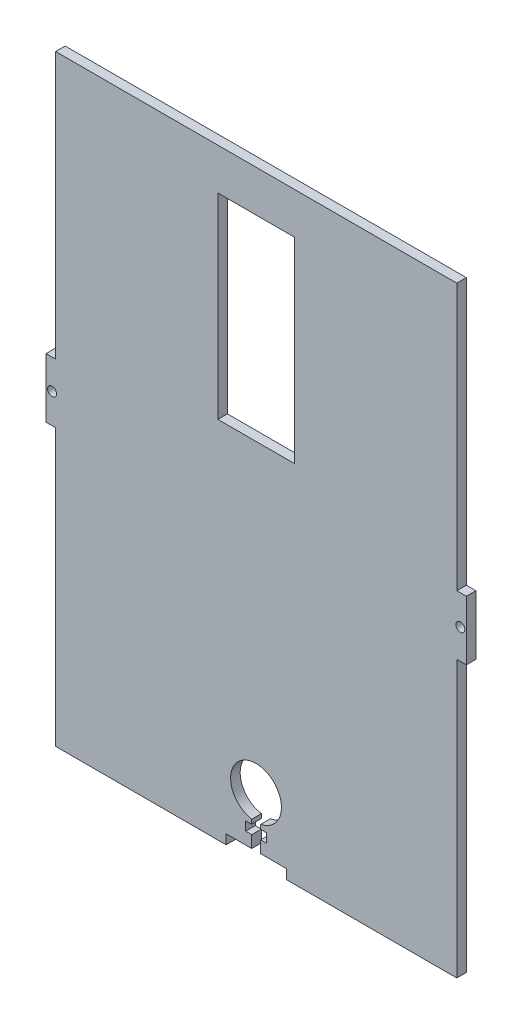
from build123d import *

# Parameters (mm, degrees)
SKETCH1_W           = 139.7
SKETCH1_H           = 203.2
BOSS_EXTRUDE1_DEPTH = 3.18
SKETCH2_R           = 1.5
SKETCH2_W           = 3.18
SKETCH2_H           = 91.725
CUT_EXTRUDE1_DEPTH  = 4.18
SKETCH3_R           = 8.441994665
CUT_EXTRUDE2_DEPTH  = 10
SKETCH5_W           = 25.530623926
SKETCH5_H           = 65.176444071
CUT_EXTRUDE3_DEPTH  = 10
SKETCH6_W           = 20.542742003
SKETCH6_H           = 14.404591712
BOSS_EXTRUDE2_DEPTH = 3.18
SKETCH7_W           = 56.63400571
SKETCH7_H           = 3.18
SKETCH7_W_2         = 56.95599429
CUT_EXTRUDE4_DEPTH  = 3.18
SKETCH8_W           = 3.18
SKETCH8_H           = 3.18
CUT_EXTRUDE5_DEPTH  = 80.56400571


with BuildPart() as part:
    # Sketch1 → Boss-Extrude1 (new body)
    with BuildSketch(Plane.XY):
        Rectangle(SKETCH1_W, SKETCH1_H)
    extrude(amount=BOSS_EXTRUDE1_DEPTH)

    # Sketch2 → Cut-Extrude1 (cut, through all)
    with BuildSketch(Plane.XY.offset(3.18)):
        with Locations((-67.85, 0)):
            Circle(SKETCH2_R)
        with Locations((67.85, 0)):
            Circle(SKETCH2_R)
        Polygon((-10, 101.6), (10, 101.6), (10, 98.42), (1.5, 98.42), (1.5, 94.42), (3.5, 94.42), (3.5, 91.42), (1.5, 91.42), (1.5, 88.42), (-1.5, 88.42), (-1.5, 91.42), (-3.5, 91.42), (-3.5, 94.42), (-1.5, 94.42), (-1.5, 98.42), (-10, 98.42), align=None)
        Polygon((-10, -101.6), (-10, -98.42), (-1.5, -98.42), (-1.5, -94.42), (-3.5, -94.42), (-3.5, -91.42), (-1.5, -91.42), (-1.5, -88.42), (1.5, -88.42), (1.5, -91.42), (3.5, -91.42), (3.5, -94.42), (1.5, -94.42), (1.5, -98.42), (10, -98.42), (10, -101.6), align=None)
        with Locations((-68.26, 55.7375)):
            Rectangle(SKETCH2_W, SKETCH2_H)
        with Locations((-68.26, -55.7375)):
            Rectangle(SKETCH2_W, SKETCH2_H)
        with Locations((68.26, -55.7375)):
            Rectangle(SKETCH2_W, SKETCH2_H)
        with Locations((68.26, 55.7375)):
            Rectangle(SKETCH2_W, SKETCH2_H)
    extrude(amount=-CUT_EXTRUDE1_DEPTH, mode=Mode.SUBTRACT)

    # Sketch3 → Cut-Extrude2 (cut)
    with BuildSketch(Plane(origin=(0, 0, 0), x_dir=(-1, 0, 0), z_dir=(0, 0, -1))):
        with Locations((0.068813102, -81.648638462)):
            Circle(SKETCH3_R)
    extrude(amount=-CUT_EXTRUDE2_DEPTH, mode=Mode.SUBTRACT)

    # Sketch5 → Cut-Extrude3 (cut)
    with BuildSketch(Plane(origin=(0, 0, 0), x_dir=(-1, 0, 0), z_dir=(0, 0, -1))):
        with Locations((0, 52.074409839)):
            Rectangle(SKETCH5_W, SKETCH5_H)
    extrude(amount=-CUT_EXTRUDE3_DEPTH, mode=Mode.SUBTRACT)

    # Sketch6 → Boss-Extrude2 (add)
    with BuildSketch(Plane(origin=(0, 0, 0), x_dir=(-1, 0, 0), z_dir=(0, 0, -1))):
        with Locations((0.271371002, 94.397704144)):
            Rectangle(SKETCH6_W, SKETCH6_H)
    extrude(amount=-BOSS_EXTRUDE2_DEPTH)

    # Sketch7 → Cut-Extrude4 (cut)
    with BuildSketch(Plane(origin=(0, 0, 0), x_dir=(-1, 0, 0), z_dir=(0, 0, -1))):
        with Locations((-38.352997145, 100.01)):
            Rectangle(SKETCH7_W, SKETCH7_H)
        with Locations((38.192002855, 100.01)):
            Rectangle(SKETCH7_W_2, SKETCH7_H)
    extrude(amount=-CUT_EXTRUDE4_DEPTH, mode=Mode.SUBTRACT)

    # Sketch8 → Cut-Extrude5 (cut, through all)
    with BuildSketch(Plane.ZY.offset(9.71400571)):
        with Locations((1.59, 100.01)):
            Rectangle(SKETCH8_W, SKETCH8_H)
    extrude(amount=-CUT_EXTRUDE5_DEPTH, mode=Mode.SUBTRACT)


solid = part.part
